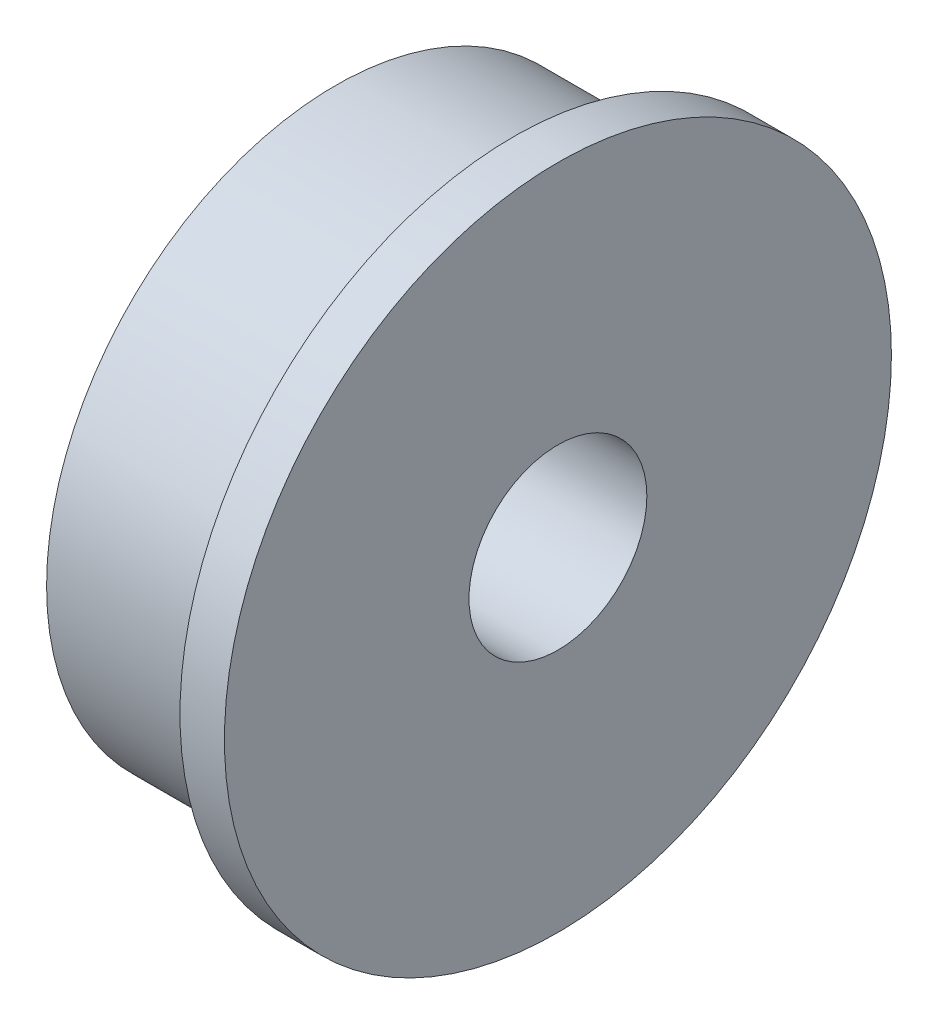
from build123d import *


with BuildPart() as part:
    # Sketch1 → Revolve1 (revolve)
    with BuildSketch(Plane.XY):
        Polygon((-0.585185185, 7.5), (-1.585185185, 7.5), (-1.585185185, 6.5), (-5.585185185, 6.5), (-5.585185185, 2), (-0.585185185, 2), align=None)
    revolve(axis=Axis((0, 0, 0), (-1, 0, 0)))


solid = part.part
